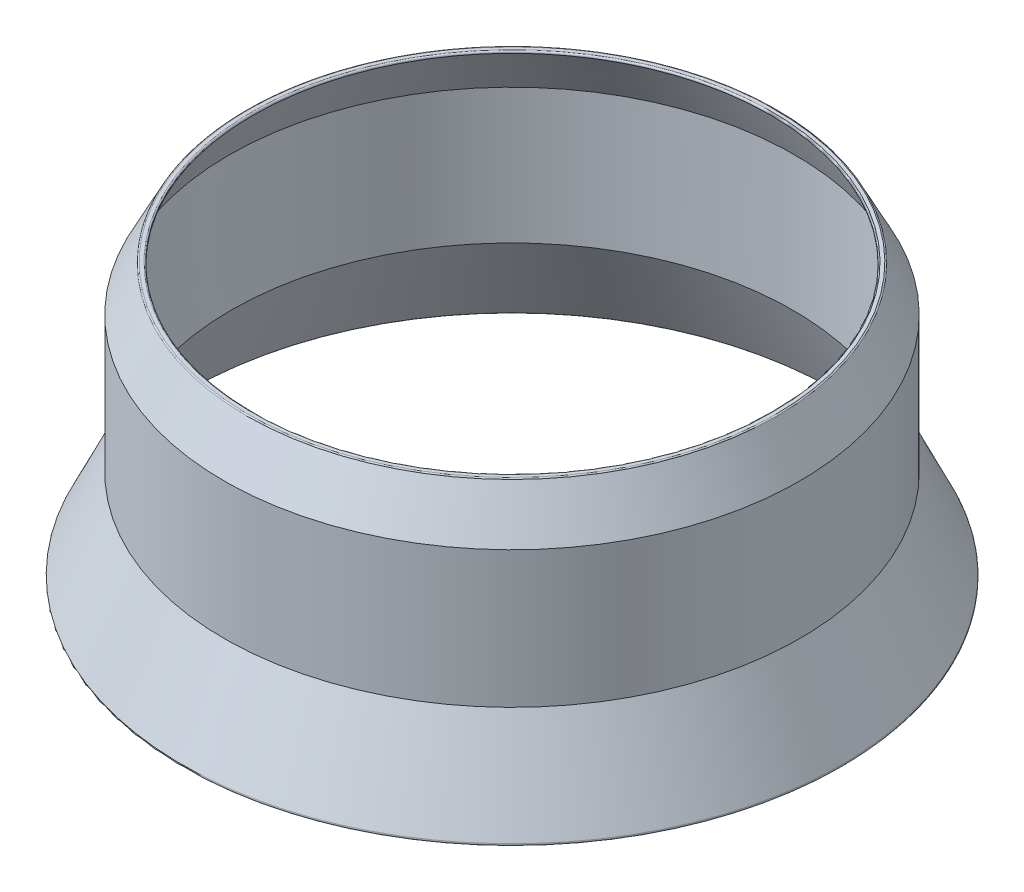
from build123d import *

# Parameters (mm, degrees)
ZAOBLIT1_R = 0.1


with BuildPart() as part:
    # Skica1 → Rotovat1 (revolve)
    with BuildSketch(Plane.XY):
        Polygon((0, 0), (1.540220403, -3), (1.540220403, -12), (4.338066352, -18), (3.87119576, -18), (1.073349812, -12), (1.184378167, -3.182691824), (-0.355842237, -0.182691824), (-0.449637462, 0), align=None)
    revolve(axis=Axis((-17.449637462, 4.842819408, 0), (0, -1, 0)))

    # Zaoblit1
    zaoblit1_edges = [part.edges().sort_by_distance(p)[0] for p in [
        (-34.449637462, 0, 0),
        (-34.899274923, 0, 0),
        (-39.237341275, -18, 0),
        (-38.770470684, -18, 0),
    ]]
    fillet(zaoblit1_edges, radius=ZAOBLIT1_R)


solid = part.part
